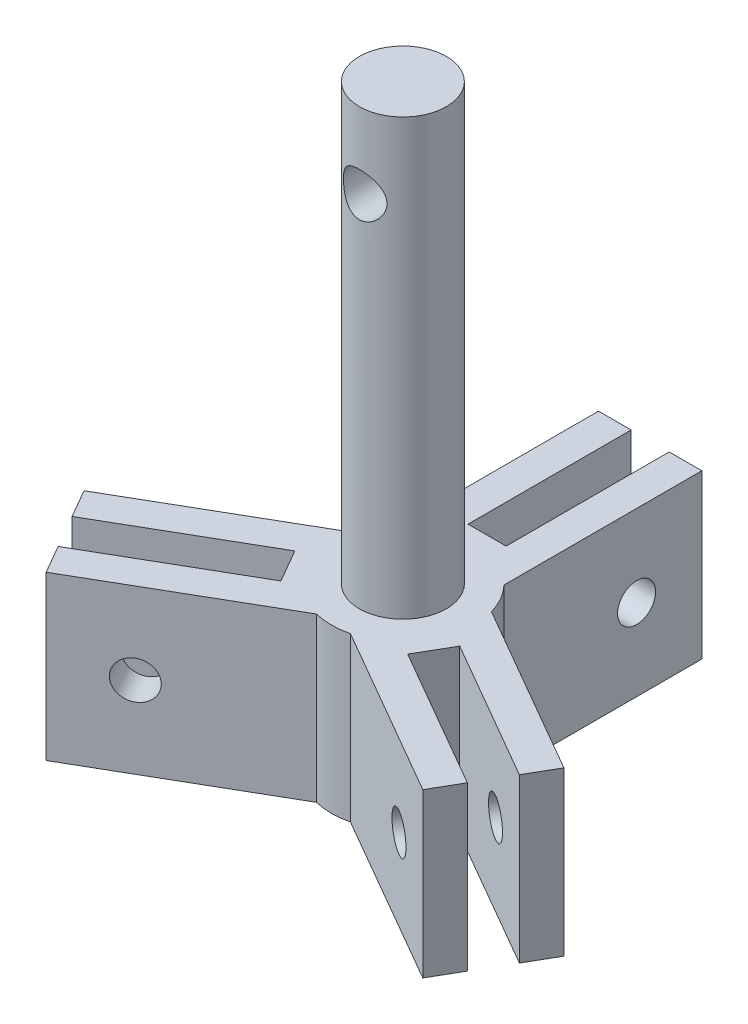
from build123d import *

# Parameters (mm, degrees)
EXTRUDE_1_DEPTH     = 15
SKETCH_2_R          = 4
EXTRUDE_2_DEPTH     = 40
SKETCH_3_R          = 1.75
CUT_EXTRUDE_1_DEPTH = 15
SKETCH_4_R          = 1.75
CUT_EXTRUDE_2_DEPTH = 15
SKETCH_5_R          = 1.75
CUT_EXTRUDE_3_DEPTH = 15
SKETCH_7_R          = 2
CUT_EXTRUDE_4_DEPTH = 15


with BuildPart() as part:
    # 草圖1 → 填料-伸長1 (new body)
    with BuildSketch(Plane(origin=(0, 0, 0), x_dir=(1, 0, 0), z_dir=(0, 1, 0))):
        with BuildLine():
            Line((6.314953067, 1.838887704), (22.070508076, -7.257586221))
            Line((22.070508076, -7.257586221), (20.570508076, -9.855662433))
            Line((20.570508076, -9.855662433), (7.580127019, -2.355662433))
            Line((7.580127019, -2.355662433), (5.830127019, -5.386751346))
            Line((5.830127019, -5.386751346), (18.820508076, -12.886751346))
            Line((18.820508076, -12.886751346), (17.320508076, -15.484827557))
            Line((17.320508076, -15.484827557), (1.564953067, -6.388353632))
            ThreePointArc((1.564953067, -6.388353632), (0, -6.577244121), (-1.564953067, -6.388353632))
            Line((-1.564953067, -6.388353632), (-17.320508076, -15.484827557))
            Line((-17.320508076, -15.484827557), (-18.820508076, -12.886751346))
            Line((-18.820508076, -12.886751346), (-5.830127019, -5.386751346))
            Line((-5.830127019, -5.386751346), (-7.580127019, -2.355662433))
            Line((-7.580127019, -2.355662433), (-20.570508076, -9.855662433))
            Line((-20.570508076, -9.855662433), (-22.070508076, -7.257586221))
            Line((-22.070508076, -7.257586221), (-6.314953067, 1.838887704))
            ThreePointArc((-6.314953067, 1.838887704), (-5.696060496, 3.28862206), (-4.75, 4.549465928))
            Line((-4.75, 4.549465928), (-4.75, 22.742413779))
            Line((-4.75, 22.742413779), (-1.75, 22.742413779))
            Line((-1.75, 22.742413779), (-1.75, 7.742413779))
            Line((-1.75, 7.742413779), (1.75, 7.742413779))
            Line((1.75, 7.742413779), (1.75, 22.742413779))
            Line((1.75, 22.742413779), (4.75, 22.742413779))
            Line((4.75, 22.742413779), (4.75, 4.549465928))
            ThreePointArc((4.75, 4.549465928), (5.696060496, 3.28862206), (6.314953067, 1.838887704))
        make_face()
    extrude(amount=EXTRUDE_1_DEPTH)

    # 草圖2 → 填料-伸長2 (add)
    with BuildSketch(Plane(origin=(0, 15, 0), x_dir=(1, 0, 0), z_dir=(0, 1, 0))):
        Circle(SKETCH_2_R)
    extrude(amount=EXTRUDE_2_DEPTH)

    # 草圖3 → 除料-伸長1 (cut)
    with BuildSketch(Plane(origin=(4.75, 0, 0), x_dir=(0, 0, -1), z_dir=(1, 0, 0))):
        with Locations((16.742413779, 7.5)):
            Circle(SKETCH_3_R)
    extrude(amount=-CUT_EXTRUDE_1_DEPTH, mode=Mode.SUBTRACT)

    # 草圖4 → 除料-伸長2 (cut)
    with BuildSketch(Plane(origin=(-2.375, 0, -4.113620668), x_dir=(-0.866025404, 0, 0.5), z_dir=(-0.5, 0, -0.866025404))):
        with Locations((16.742413779, 7.5)):
            Circle(SKETCH_4_R)
    extrude(amount=-CUT_EXTRUDE_2_DEPTH, mode=Mode.SUBTRACT)

    # 草圖5 → 除料-伸長3 (cut)
    with BuildSketch(Plane(origin=(-2.375, 0, 4.113620668), x_dir=(0.866025404, 0, 0.5), z_dir=(-0.5, 0, 0.866025404))):
        with Locations((16.742413779, 7.5)):
            Circle(SKETCH_5_R)
    extrude(amount=-CUT_EXTRUDE_3_DEPTH, mode=Mode.SUBTRACT)

    # 草圖7 → 除料-伸長4 (cut)
    with BuildSketch(Plane.XY.offset(4)):
        with Locations((0, 48)):
            Circle(SKETCH_7_R)
    extrude(amount=-CUT_EXTRUDE_4_DEPTH, mode=Mode.SUBTRACT)


solid = part.part
